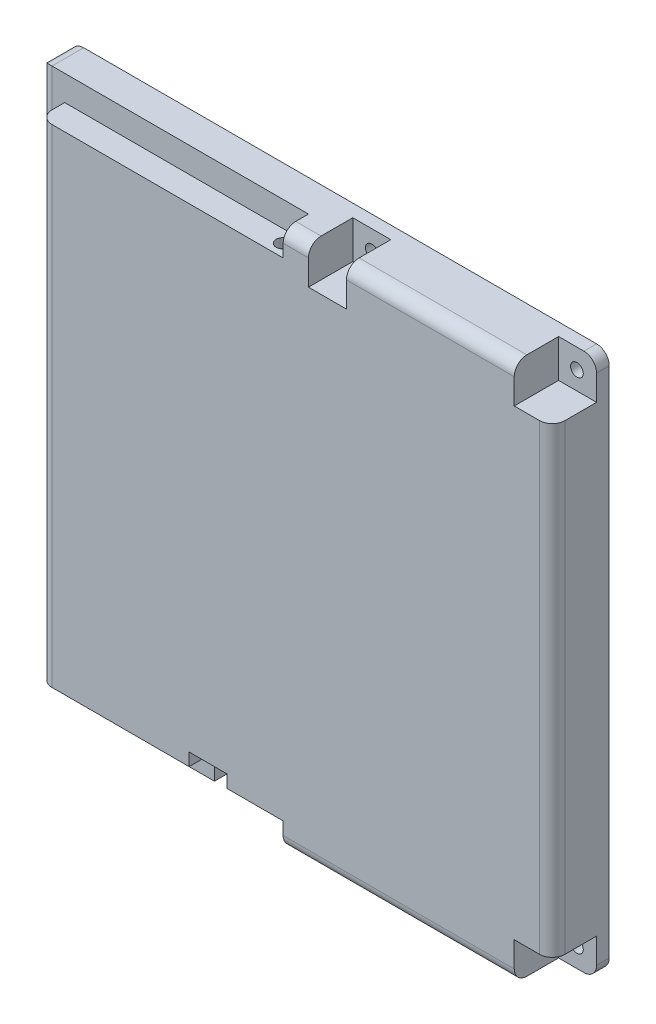
from build123d import *

# Parameters (mm, degrees)
EXTRUDE_1_DEPTH     = 9
CUT_EXTRUDE_2_DEPTH = 4
SKETCH_7_W          = 6
SKETCH_7_H          = 6
CUT_EXTRUDE_4_DEPTH = 7
SKETCH_10_W         = 6
SKETCH_10_H         = 6
CUT_EXTRUDE_6_DEPTH = 7
SHELL_1_T           = -1.5
SKETCH_5_R          = 1.1
CUT_EXTRUDE_3_DEPTH = 4
CUT_EXTRUDE_START   = -9
SKETCH_6_R          = 1
CUT_EXTRUDE_5_DEPTH = 7.5
FILLET_1_R          = 2
CUT_EXTRUDE_7_REACH = 4
SKETCH_12_R         = 1


with BuildPart() as part:
    # 草图1 → 凸台-拉伸1 (new body)
    with BuildSketch(Plane.XY):
        Polygon((70.444808084, 16.058078986), (70.444808084, -68.941921014), (155.445322416, -68.941921014), (155.444808084, 16.058078986), align=None)
    extrude(amount=EXTRUDE_1_DEPTH)

    # 草图4 → 支架切除-拉伸2 (cut)
    with BuildSketch(Plane.XY.offset(9)):
        Polygon((112.94506525, 16.058078986), (70.444808084, 16.058078986), (70.444808084, -68.941921014), (112.94506525, -68.941921014), (112.94506525, -64.941921014), (74.444808084, -64.941921014), (74.444808084, 12.058078986), (112.94506525, 12.058078986), align=None)
    extrude(amount=-CUT_EXTRUDE_2_DEPTH, mode=Mode.SUBTRACT)

    # 草图7 → 顶螺丝切除-拉伸4 (cut)
    with BuildSketch(Plane.XY.offset(9)):
        with Locations((152.445322416, 13.058078986)):
            Rectangle(SKETCH_7_W, SKETCH_7_H)
        with Locations((152.445322416, -65.941921014)):
            Rectangle(SKETCH_7_W, SKETCH_7_H)
    extrude(amount=-CUT_EXTRUDE_4_DEPTH, mode=Mode.SUBTRACT)

    # 草图10 → 底螺丝切除-拉伸6 (cut)
    with BuildSketch(Plane.XY.offset(9)):
        with Locations((119.944808084, 13.058078986)):
            Rectangle(SKETCH_10_W, SKETCH_10_H)
        with Locations((101.094808084, -65.941921014)):
            Rectangle(SKETCH_10_W, SKETCH_10_H)
    extrude(amount=-CUT_EXTRUDE_6_DEPTH, mode=Mode.SUBTRACT)

    # 抽壳1
    shell_1_openings = [part.faces().sort_by_distance(p)[0] for p in [
        (112.94506525, -26.441921014, 0),
    ]]
    offset(amount=SHELL_1_T, openings=shell_1_openings, kind=Kind.INTERSECTION)

    # 草图5 → 切除-拉伸3 (cut)
    with BuildSketch(Plane(origin=(0, 12.058078986, 0), x_dir=(1, 0, 0), z_dir=(0, 1, 0))):
        with Locations((110.94506525, -7)):
            Circle(SKETCH_5_R)
    cut_extrude_3 = extrude(amount=-CUT_EXTRUDE_3_DEPTH, mode=Mode.SUBTRACT)

    # 镜向1: 切除-拉伸3 across plane
    add(cut_extrude_3.mirror(Plane.ZX.offset(-26.441921014)), mode=Mode.SUBTRACT)

    # 草图6 → 顶螺丝切除-拉伸5 (cut)
    with BuildSketch(Plane.XY.offset(9).offset(CUT_EXTRUDE_START)):
        with Locations((152.344808084, 12.958078986)):
            Circle(SKETCH_6_R)
        with Locations((152.344808084, -65.841921014)):
            Circle(SKETCH_6_R)
    extrude(amount=CUT_EXTRUDE_5_DEPTH, mode=Mode.SUBTRACT)

    # 圆角1
    fillet_1_edges = [part.edges().sort_by_distance(p)[0] for p in [
        (131.195193833, -68.941921014, 9),
        (70.444808084, 16.058078986, 2.5),
        (70.444808084, -68.941921014, 2.5),
        (70.444808084, -26.441921014, 5),
        (74.444808084, -26.441921014, 9),
        (155.44506525, -26.441921014, 9),
        (136.19506525, 16.058078986, 9),
        (155.444808084, 16.058078986, 1),
        (155.445322416, -68.941921014, 1),
        (114.944936667, 16.058078986, 9),
    ]]
    fillet(fillet_1_edges, radius=FILLET_1_R)

    # 草图12 → 底螺丝切除-拉伸7 (cut, up to next)
    with BuildSketch(Plane.XY.offset(2), mode=Mode.PRIVATE) as cut_extrude_7_sk1:
        with Locations((119.944808084, 12.958078986)):
            Circle(SKETCH_12_R)
    cut_extrude_7_tool1 = extrude(cut_extrude_7_sk1.sketch, amount=-CUT_EXTRUDE_7_REACH, mode=Mode.PRIVATE) & part.part
    add(cut_extrude_7_tool1.solids().sort_by_distance((119.944808, 12.958079, 2))[0], mode=Mode.SUBTRACT)
    # 草图12 → 底螺丝切除-拉伸7 (cut, up to next)
    with BuildSketch(Plane.XY.offset(2), mode=Mode.PRIVATE) as cut_extrude_7_sk2:
        with Locations((101.094808084, -65.841921014)):
            Circle(SKETCH_12_R)
    cut_extrude_7_tool2 = extrude(cut_extrude_7_sk2.sketch, amount=-CUT_EXTRUDE_7_REACH, mode=Mode.PRIVATE) & part.part
    add(cut_extrude_7_tool2.solids().sort_by_distance((101.094808, -65.841921, 2))[0], mode=Mode.SUBTRACT)


solid = part.part
